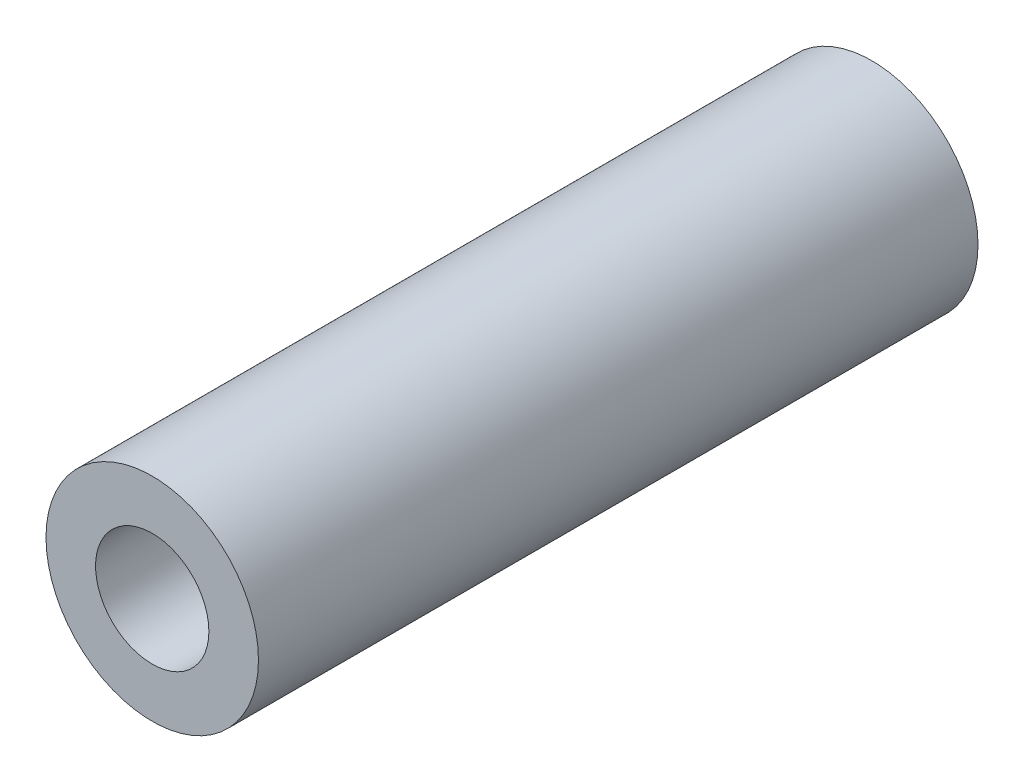
from build123d import *

# Parameters (mm, degrees)
SKETCH1_R           = 3.75
SKETCH1_R_2         = 2
BOSS_EXTRUDE1_DEPTH = 25.4


with BuildPart() as part:
    # Sketch1 → Boss-Extrude1 (new body)
    with BuildSketch(Plane.XY):
        Circle(SKETCH1_R)
        Circle(SKETCH1_R_2, mode=Mode.SUBTRACT)
    extrude(amount=BOSS_EXTRUDE1_DEPTH)


solid = part.part
